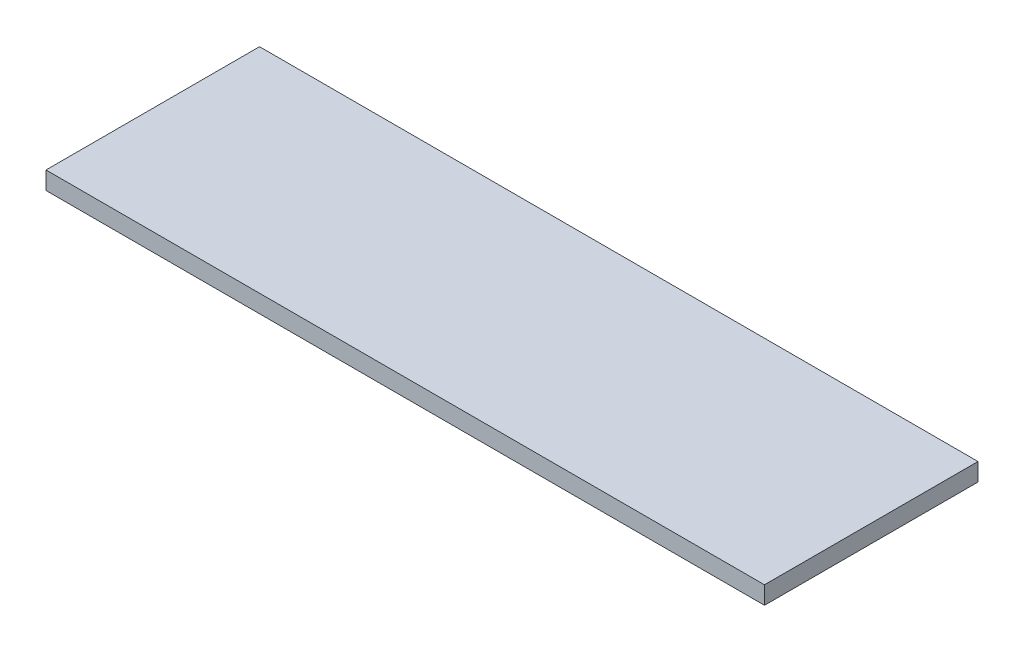
from build123d import *

# Parameters (mm, degrees)
SKETCH1_W           = 128.199999886
SKETCH1_H           = 38.1
BOSS_EXTRUDE1_DEPTH = 3.175


with BuildPart() as part:
    # Sketch1 → Boss-Extrude1 (new body)
    with BuildSketch(Plane(origin=(0, 0, 0), x_dir=(1, 0, 0), z_dir=(0, 1, 0))):
        Rectangle(SKETCH1_W, SKETCH1_H)
    extrude(amount=BOSS_EXTRUDE1_DEPTH)


solid = part.part
